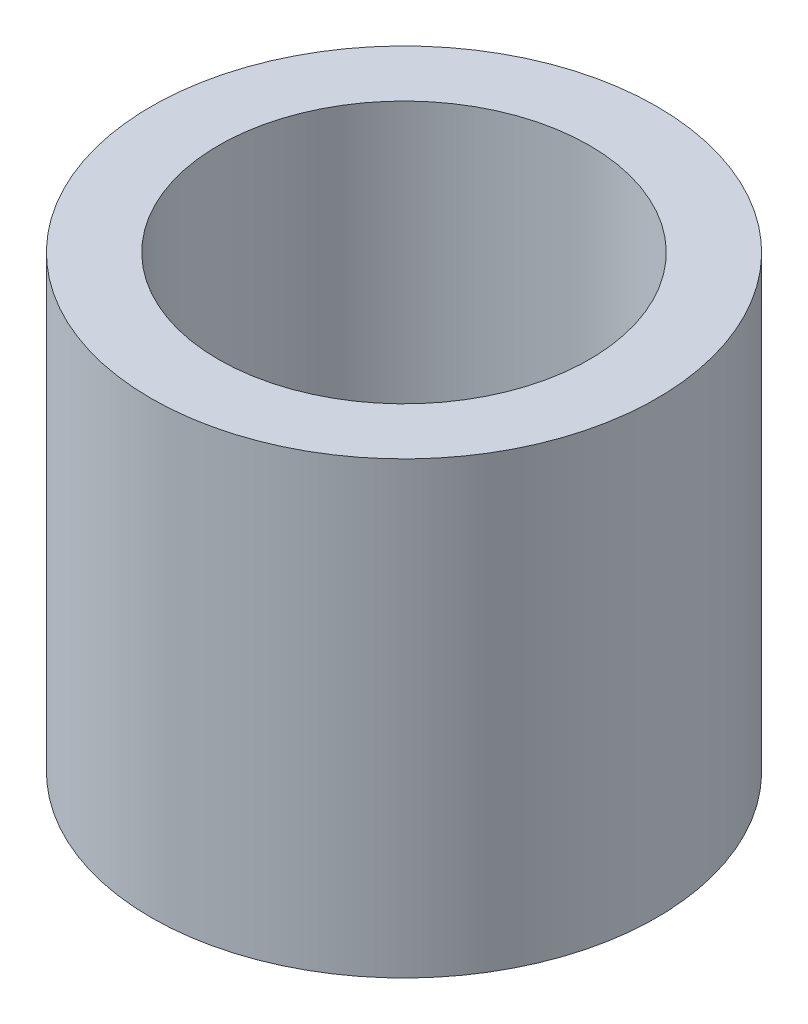
from build123d import *

# Parameters (mm, degrees)
SKETCH1_R           = 5.715
SKETCH1_R_2         = 4.191
BOSS_EXTRUDE1_DEPTH = 5.08


with BuildPart() as part:
    # Sketch1 → Boss-Extrude1 (new body, symmetric)
    with BuildSketch(Plane(origin=(0, 0, 0), x_dir=(1, 0, 0), z_dir=(0, 1, 0))):
        Circle(SKETCH1_R)
        Circle(SKETCH1_R_2, mode=Mode.SUBTRACT)
    extrude(amount=BOSS_EXTRUDE1_DEPTH, both=True)


solid = part.part
